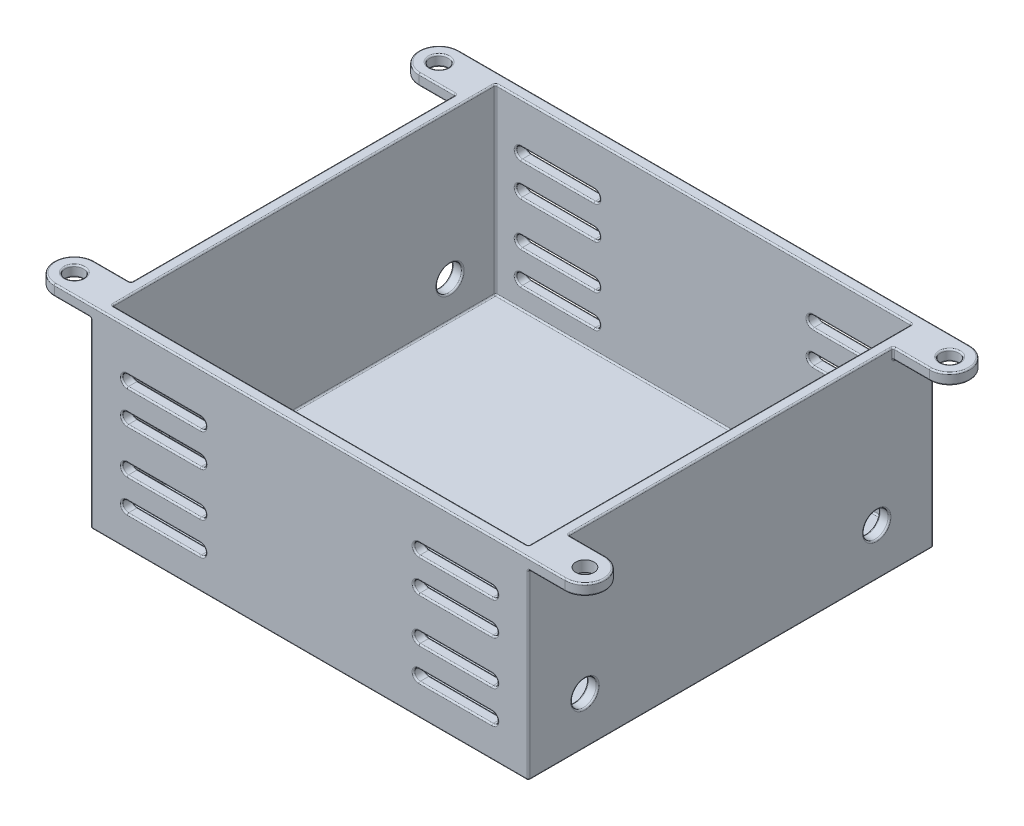
from build123d import *

# Parameters (mm, degrees)
SKETCH1_W                      = 60
SKETCH1_H                      = 55.5
SKETCH1_W_2                    = 57
SKETCH1_H_2                    = 52.5
BOSS_EXTRUDE1_DEPTH            = 25
SKETCH2_W                      = 60
SKETCH2_H                      = 55.5
BOSS_EXTRUDE2_DEPTH            = 1.5
SKETCH4_R                      = 1.25
BOSS_EXTRUDE3_DEPTH            = 1.5
CUT_EXTRUDE1_REACH             = 29.75
CUT_EXTRUDE1_DIRECTION_2_REACH = 29.75
CUT_EXTRUDE2_REACH             = 39.75
SKETCH7_R                      = 1.75
CUT_EXTRUDE2_DIRECTION_2_REACH = 39.75
FILLET1_R                      = 0.2
SKETCH8_R                      = 1.25
CUT_EXTRUDE3_DEPTH             = 10


with BuildPart() as part:
    # Sketch1 → Boss-Extrude1 (new body)
    with BuildSketch(Plane(origin=(0, 0, 0), x_dir=(1, 0, 0), z_dir=(0, 1, 0))):
        Rectangle(SKETCH1_W, SKETCH1_H)
        Rectangle(SKETCH1_W_2, SKETCH1_H_2, mode=Mode.SUBTRACT)
    extrude(amount=-BOSS_EXTRUDE1_DEPTH)

    # Sketch2 → Boss-Extrude2 (add)
    with BuildSketch(Plane.XZ.offset(25)):
        Rectangle(SKETCH2_W, SKETCH2_H)
    extrude(amount=BOSS_EXTRUDE2_DEPTH)

    # Sketch4 → Boss-Extrude3 (add)
    with BuildSketch(Plane(origin=(0, 0, 0), x_dir=(1, 0, 0), z_dir=(0, 1, 0))):
        with BuildLine():
            Line((-30, 22.25), (-30, 27.75))
            Line((-30, 27.75), (-35, 27.75))
            ThreePointArc((-35, 27.75), (-37.75, 25), (-35, 22.25))
            Line((-35, 22.25), (-30, 22.25))
        make_face()
        with Locations((-35, 25)):
            Circle(SKETCH4_R, mode=Mode.SUBTRACT)
        with BuildLine():
            Line((35, 27.75), (30, 27.75))
            Line((30, 27.75), (30, 22.25))
            Line((30, 22.25), (35, 22.25))
            ThreePointArc((35, 22.25), (37.75, 25), (35, 27.75))
        make_face()
        with Locations((35, 25)):
            Circle(SKETCH4_R, mode=Mode.SUBTRACT)
        with BuildLine():
            Line((-30, -27.75), (-30, -22.25))
            Line((-30, -22.25), (-35, -22.25))
            ThreePointArc((-35, -22.25), (-37.75, -25), (-35, -27.75))
            Line((-35, -27.75), (-30, -27.75))
        make_face()
        with Locations((-35, -25)):
            Circle(SKETCH4_R, mode=Mode.SUBTRACT)
        with BuildLine():
            Line((35, -22.25), (30, -22.25))
            Line((30, -22.25), (30, -27.75))
            Line((30, -27.75), (35, -27.75))
            ThreePointArc((35, -27.75), (37.75, -25), (35, -22.25))
        make_face()
    extrude(amount=-BOSS_EXTRUDE3_DEPTH)

    # Cut-Extrude1: up to this face of the body (flat: up to its plane)
    cut_extrude1_end = Plane(part.part.faces().sort_by_distance((0, -13.13317757, -27.75))[0])
    # Sketch5 → Cut-Extrude1 (cut, up to the picked face)
    with BuildSketch(Plane.XY, mode=Mode.PRIVATE) as cut_extrude1_sk1:
        with BuildLine():
            Line((-25, -5.75), (-15, -5.75))
            ThreePointArc((-15, -5.75), (-14.25, -6.5), (-15, -7.25))
            Line((-15, -7.25), (-25, -7.25))
            ThreePointArc((-25, -7.25), (-25.75, -6.5), (-25, -5.75))
        make_face()
    cut_extrude1_tool1 = split(extrude(cut_extrude1_sk1.sketch, amount=-CUT_EXTRUDE1_REACH, mode=Mode.PRIVATE), bisect_by=cut_extrude1_end, keep=Keep.BOTH, mode=Mode.PRIVATE)
    add(cut_extrude1_tool1.solids().sort_by_distance((-20, -6.5, 0))[0], mode=Mode.SUBTRACT)
    # Sketch5 → Cut-Extrude1 (cut, up to the picked face)
    with BuildSketch(Plane.XY, mode=Mode.PRIVATE) as cut_extrude1_sk2:
        with BuildLine():
            Line((-25, -10.25), (-15, -10.25))
            ThreePointArc((-15, -10.25), (-14.25, -11), (-15, -11.75))
            Line((-15, -11.75), (-25, -11.75))
            ThreePointArc((-25, -11.75), (-25.75, -11), (-25, -10.25))
        make_face()
    cut_extrude1_tool2 = split(extrude(cut_extrude1_sk2.sketch, amount=-CUT_EXTRUDE1_REACH, mode=Mode.PRIVATE), bisect_by=cut_extrude1_end, keep=Keep.BOTH, mode=Mode.PRIVATE)
    add(cut_extrude1_tool2.solids().sort_by_distance((-20, -11, 0))[0], mode=Mode.SUBTRACT)
    # Sketch5 → Cut-Extrude1 (cut, up to the picked face)
    with BuildSketch(Plane.XY, mode=Mode.PRIVATE) as cut_extrude1_sk3:
        with BuildLine():
            Line((-25, -22.25), (-15, -22.25))
            ThreePointArc((-15, -22.25), (-14.25, -21.5), (-15, -20.75))
            Line((-15, -20.75), (-25, -20.75))
            ThreePointArc((-25, -20.75), (-25.75, -21.5), (-25, -22.25))
        make_face()
    cut_extrude1_tool3 = split(extrude(cut_extrude1_sk3.sketch, amount=-CUT_EXTRUDE1_REACH, mode=Mode.PRIVATE), bisect_by=cut_extrude1_end, keep=Keep.BOTH, mode=Mode.PRIVATE)
    add(cut_extrude1_tool3.solids().sort_by_distance((-20, -21.5, 0))[0], mode=Mode.SUBTRACT)
    # Sketch5 → Cut-Extrude1 (cut, up to the picked face)
    with BuildSketch(Plane.XY, mode=Mode.PRIVATE) as cut_extrude1_sk4:
        with BuildLine():
            Line((-25, -17.75), (-15, -17.75))
            ThreePointArc((-15, -17.75), (-14.25, -17), (-15, -16.25))
            Line((-15, -16.25), (-25, -16.25))
            ThreePointArc((-25, -16.25), (-25.75, -17), (-25, -17.75))
        make_face()
    cut_extrude1_tool4 = split(extrude(cut_extrude1_sk4.sketch, amount=-CUT_EXTRUDE1_REACH, mode=Mode.PRIVATE), bisect_by=cut_extrude1_end, keep=Keep.BOTH, mode=Mode.PRIVATE)
    add(cut_extrude1_tool4.solids().sort_by_distance((-20, -17, 0))[0], mode=Mode.SUBTRACT)
    # Sketch5 → Cut-Extrude1 (cut, up to the picked face)
    with BuildSketch(Plane.XY, mode=Mode.PRIVATE) as cut_extrude1_sk5:
        with BuildLine():
            Line((25, -5.75), (15, -5.75))
            ThreePointArc((15, -5.75), (14.25, -6.5), (15, -7.25))
            Line((15, -7.25), (25, -7.25))
            ThreePointArc((25, -7.25), (25.75, -6.5), (25, -5.75))
        make_face()
    cut_extrude1_tool5 = split(extrude(cut_extrude1_sk5.sketch, amount=-CUT_EXTRUDE1_REACH, mode=Mode.PRIVATE), bisect_by=cut_extrude1_end, keep=Keep.BOTH, mode=Mode.PRIVATE)
    add(cut_extrude1_tool5.solids().sort_by_distance((20, -6.5, 0))[0], mode=Mode.SUBTRACT)
    # Sketch5 → Cut-Extrude1 (cut, up to the picked face)
    with BuildSketch(Plane.XY, mode=Mode.PRIVATE) as cut_extrude1_sk6:
        with BuildLine():
            Line((25, -10.25), (15, -10.25))
            ThreePointArc((15, -10.25), (14.25, -11), (15, -11.75))
            Line((15, -11.75), (25, -11.75))
            ThreePointArc((25, -11.75), (25.75, -11), (25, -10.25))
        make_face()
    cut_extrude1_tool6 = split(extrude(cut_extrude1_sk6.sketch, amount=-CUT_EXTRUDE1_REACH, mode=Mode.PRIVATE), bisect_by=cut_extrude1_end, keep=Keep.BOTH, mode=Mode.PRIVATE)
    add(cut_extrude1_tool6.solids().sort_by_distance((20, -11, 0))[0], mode=Mode.SUBTRACT)
    # Sketch5 → Cut-Extrude1 (cut, up to the picked face)
    with BuildSketch(Plane.XY, mode=Mode.PRIVATE) as cut_extrude1_sk7:
        with BuildLine():
            Line((25, -22.25), (15, -22.25))
            ThreePointArc((15, -22.25), (14.25, -21.5), (15, -20.75))
            Line((15, -20.75), (25, -20.75))
            ThreePointArc((25, -20.75), (25.75, -21.5), (25, -22.25))
        make_face()
    cut_extrude1_tool7 = split(extrude(cut_extrude1_sk7.sketch, amount=-CUT_EXTRUDE1_REACH, mode=Mode.PRIVATE), bisect_by=cut_extrude1_end, keep=Keep.BOTH, mode=Mode.PRIVATE)
    add(cut_extrude1_tool7.solids().sort_by_distance((20, -21.5, 0))[0], mode=Mode.SUBTRACT)
    # Sketch5 → Cut-Extrude1 (cut, up to the picked face)
    with BuildSketch(Plane.XY, mode=Mode.PRIVATE) as cut_extrude1_sk8:
        with BuildLine():
            Line((25, -17.75), (15, -17.75))
            ThreePointArc((15, -17.75), (14.25, -17), (15, -16.25))
            Line((15, -16.25), (25, -16.25))
            ThreePointArc((25, -16.25), (25.75, -17), (25, -17.75))
        make_face()
    cut_extrude1_tool8 = split(extrude(cut_extrude1_sk8.sketch, amount=-CUT_EXTRUDE1_REACH, mode=Mode.PRIVATE), bisect_by=cut_extrude1_end, keep=Keep.BOTH, mode=Mode.PRIVATE)
    add(cut_extrude1_tool8.solids().sort_by_distance((20, -17, 0))[0], mode=Mode.SUBTRACT)

    # Cut-Extrude1 direction 2: up to this face of the body (flat: up to its plane)
    cut_extrude1_direction_2_end = Plane(part.part.faces().sort_by_distance((0, -13.13317757, 27.75))[0])
    # Sketch5 → Cut-Extrude1 direction 2 (cut, up to the picked face)
    with BuildSketch(Plane.XY, mode=Mode.PRIVATE) as cut_extrude1_direction_2_sk1:
        with BuildLine():
            Line((-25, -5.75), (-15, -5.75))
            ThreePointArc((-15, -5.75), (-14.25, -6.5), (-15, -7.25))
            Line((-15, -7.25), (-25, -7.25))
            ThreePointArc((-25, -7.25), (-25.75, -6.5), (-25, -5.75))
        make_face()
    cut_extrude1_direction_2_tool1 = split(extrude(cut_extrude1_direction_2_sk1.sketch, amount=CUT_EXTRUDE1_DIRECTION_2_REACH, mode=Mode.PRIVATE), bisect_by=cut_extrude1_direction_2_end, keep=Keep.BOTH, mode=Mode.PRIVATE)
    add(cut_extrude1_direction_2_tool1.solids().sort_by_distance((-20, -6.5, 0))[0], mode=Mode.SUBTRACT)
    # Sketch5 → Cut-Extrude1 direction 2 (cut, up to the picked face)
    with BuildSketch(Plane.XY, mode=Mode.PRIVATE) as cut_extrude1_direction_2_sk2:
        with BuildLine():
            Line((-25, -10.25), (-15, -10.25))
            ThreePointArc((-15, -10.25), (-14.25, -11), (-15, -11.75))
            Line((-15, -11.75), (-25, -11.75))
            ThreePointArc((-25, -11.75), (-25.75, -11), (-25, -10.25))
        make_face()
    cut_extrude1_direction_2_tool2 = split(extrude(cut_extrude1_direction_2_sk2.sketch, amount=CUT_EXTRUDE1_DIRECTION_2_REACH, mode=Mode.PRIVATE), bisect_by=cut_extrude1_direction_2_end, keep=Keep.BOTH, mode=Mode.PRIVATE)
    add(cut_extrude1_direction_2_tool2.solids().sort_by_distance((-20, -11, 0))[0], mode=Mode.SUBTRACT)
    # Sketch5 → Cut-Extrude1 direction 2 (cut, up to the picked face)
    with BuildSketch(Plane.XY, mode=Mode.PRIVATE) as cut_extrude1_direction_2_sk3:
        with BuildLine():
            Line((-25, -22.25), (-15, -22.25))
            ThreePointArc((-15, -22.25), (-14.25, -21.5), (-15, -20.75))
            Line((-15, -20.75), (-25, -20.75))
            ThreePointArc((-25, -20.75), (-25.75, -21.5), (-25, -22.25))
        make_face()
    cut_extrude1_direction_2_tool3 = split(extrude(cut_extrude1_direction_2_sk3.sketch, amount=CUT_EXTRUDE1_DIRECTION_2_REACH, mode=Mode.PRIVATE), bisect_by=cut_extrude1_direction_2_end, keep=Keep.BOTH, mode=Mode.PRIVATE)
    add(cut_extrude1_direction_2_tool3.solids().sort_by_distance((-20, -21.5, 0))[0], mode=Mode.SUBTRACT)
    # Sketch5 → Cut-Extrude1 direction 2 (cut, up to the picked face)
    with BuildSketch(Plane.XY, mode=Mode.PRIVATE) as cut_extrude1_direction_2_sk4:
        with BuildLine():
            Line((-25, -17.75), (-15, -17.75))
            ThreePointArc((-15, -17.75), (-14.25, -17), (-15, -16.25))
            Line((-15, -16.25), (-25, -16.25))
            ThreePointArc((-25, -16.25), (-25.75, -17), (-25, -17.75))
        make_face()
    cut_extrude1_direction_2_tool4 = split(extrude(cut_extrude1_direction_2_sk4.sketch, amount=CUT_EXTRUDE1_DIRECTION_2_REACH, mode=Mode.PRIVATE), bisect_by=cut_extrude1_direction_2_end, keep=Keep.BOTH, mode=Mode.PRIVATE)
    add(cut_extrude1_direction_2_tool4.solids().sort_by_distance((-20, -17, 0))[0], mode=Mode.SUBTRACT)
    # Sketch5 → Cut-Extrude1 direction 2 (cut, up to the picked face)
    with BuildSketch(Plane.XY, mode=Mode.PRIVATE) as cut_extrude1_direction_2_sk5:
        with BuildLine():
            Line((25, -5.75), (15, -5.75))
            ThreePointArc((15, -5.75), (14.25, -6.5), (15, -7.25))
            Line((15, -7.25), (25, -7.25))
            ThreePointArc((25, -7.25), (25.75, -6.5), (25, -5.75))
        make_face()
    cut_extrude1_direction_2_tool5 = split(extrude(cut_extrude1_direction_2_sk5.sketch, amount=CUT_EXTRUDE1_DIRECTION_2_REACH, mode=Mode.PRIVATE), bisect_by=cut_extrude1_direction_2_end, keep=Keep.BOTH, mode=Mode.PRIVATE)
    add(cut_extrude1_direction_2_tool5.solids().sort_by_distance((20, -6.5, 0))[0], mode=Mode.SUBTRACT)
    # Sketch5 → Cut-Extrude1 direction 2 (cut, up to the picked face)
    with BuildSketch(Plane.XY, mode=Mode.PRIVATE) as cut_extrude1_direction_2_sk6:
        with BuildLine():
            Line((25, -10.25), (15, -10.25))
            ThreePointArc((15, -10.25), (14.25, -11), (15, -11.75))
            Line((15, -11.75), (25, -11.75))
            ThreePointArc((25, -11.75), (25.75, -11), (25, -10.25))
        make_face()
    cut_extrude1_direction_2_tool6 = split(extrude(cut_extrude1_direction_2_sk6.sketch, amount=CUT_EXTRUDE1_DIRECTION_2_REACH, mode=Mode.PRIVATE), bisect_by=cut_extrude1_direction_2_end, keep=Keep.BOTH, mode=Mode.PRIVATE)
    add(cut_extrude1_direction_2_tool6.solids().sort_by_distance((20, -11, 0))[0], mode=Mode.SUBTRACT)
    # Sketch5 → Cut-Extrude1 direction 2 (cut, up to the picked face)
    with BuildSketch(Plane.XY, mode=Mode.PRIVATE) as cut_extrude1_direction_2_sk7:
        with BuildLine():
            Line((25, -22.25), (15, -22.25))
            ThreePointArc((15, -22.25), (14.25, -21.5), (15, -20.75))
            Line((15, -20.75), (25, -20.75))
            ThreePointArc((25, -20.75), (25.75, -21.5), (25, -22.25))
        make_face()
    cut_extrude1_direction_2_tool7 = split(extrude(cut_extrude1_direction_2_sk7.sketch, amount=CUT_EXTRUDE1_DIRECTION_2_REACH, mode=Mode.PRIVATE), bisect_by=cut_extrude1_direction_2_end, keep=Keep.BOTH, mode=Mode.PRIVATE)
    add(cut_extrude1_direction_2_tool7.solids().sort_by_distance((20, -21.5, 0))[0], mode=Mode.SUBTRACT)
    # Sketch5 → Cut-Extrude1 direction 2 (cut, up to the picked face)
    with BuildSketch(Plane.XY, mode=Mode.PRIVATE) as cut_extrude1_direction_2_sk8:
        with BuildLine():
            Line((25, -17.75), (15, -17.75))
            ThreePointArc((15, -17.75), (14.25, -17), (15, -16.25))
            Line((15, -16.25), (25, -16.25))
            ThreePointArc((25, -16.25), (25.75, -17), (25, -17.75))
        make_face()
    cut_extrude1_direction_2_tool8 = split(extrude(cut_extrude1_direction_2_sk8.sketch, amount=CUT_EXTRUDE1_DIRECTION_2_REACH, mode=Mode.PRIVATE), bisect_by=cut_extrude1_direction_2_end, keep=Keep.BOTH, mode=Mode.PRIVATE)
    add(cut_extrude1_direction_2_tool8.solids().sort_by_distance((20, -17, 0))[0], mode=Mode.SUBTRACT)

    # Cut-Extrude2: up to this face of the body (flat: up to its plane)
    cut_extrude2_end = Plane(part.part.faces().sort_by_distance((30, -13.391825683, 0))[0])
    # Sketch7 → Cut-Extrude2 (cut, up to the picked face)
    with BuildSketch(Plane(origin=(0, 0, 0), x_dir=(0, 0, -1), z_dir=(1, 0, 0)), mode=Mode.PRIVATE) as cut_extrude2_sk1:
        with Locations((-20, -20)):
            Circle(SKETCH7_R)
    cut_extrude2_tool1 = split(extrude(cut_extrude2_sk1.sketch, amount=CUT_EXTRUDE2_REACH, mode=Mode.PRIVATE), bisect_by=cut_extrude2_end, keep=Keep.BOTH, mode=Mode.PRIVATE)
    add(cut_extrude2_tool1.solids().sort_by_distance((0, -20, 20))[0], mode=Mode.SUBTRACT)
    # Sketch7 → Cut-Extrude2 (cut, up to the picked face)
    with BuildSketch(Plane(origin=(0, 0, 0), x_dir=(0, 0, -1), z_dir=(1, 0, 0)), mode=Mode.PRIVATE) as cut_extrude2_sk2:
        with Locations((20, -20)):
            Circle(SKETCH7_R)
    cut_extrude2_tool2 = split(extrude(cut_extrude2_sk2.sketch, amount=CUT_EXTRUDE2_REACH, mode=Mode.PRIVATE), bisect_by=cut_extrude2_end, keep=Keep.BOTH, mode=Mode.PRIVATE)
    add(cut_extrude2_tool2.solids().sort_by_distance((0, -20, -20))[0], mode=Mode.SUBTRACT)

    # Cut-Extrude2 direction 2: up to this face of the body (flat: up to its plane)
    cut_extrude2_direction_2_end = Plane(part.part.faces().sort_by_distance((-30, -13.391825683, 0))[0])
    # Sketch7 → Cut-Extrude2 direction 2 (cut, up to the picked face)
    with BuildSketch(Plane(origin=(0, 0, 0), x_dir=(0, 0, -1), z_dir=(1, 0, 0)), mode=Mode.PRIVATE) as cut_extrude2_direction_2_sk1:
        with Locations((-20, -20)):
            Circle(SKETCH7_R)
    cut_extrude2_direction_2_tool1 = split(extrude(cut_extrude2_direction_2_sk1.sketch, amount=-CUT_EXTRUDE2_DIRECTION_2_REACH, mode=Mode.PRIVATE), bisect_by=cut_extrude2_direction_2_end, keep=Keep.BOTH, mode=Mode.PRIVATE)
    add(cut_extrude2_direction_2_tool1.solids().sort_by_distance((0, -20, 20))[0], mode=Mode.SUBTRACT)
    # Sketch7 → Cut-Extrude2 direction 2 (cut, up to the picked face)
    with BuildSketch(Plane(origin=(0, 0, 0), x_dir=(0, 0, -1), z_dir=(1, 0, 0)), mode=Mode.PRIVATE) as cut_extrude2_direction_2_sk2:
        with Locations((20, -20)):
            Circle(SKETCH7_R)
    cut_extrude2_direction_2_tool2 = split(extrude(cut_extrude2_direction_2_sk2.sketch, amount=-CUT_EXTRUDE2_DIRECTION_2_REACH, mode=Mode.PRIVATE), bisect_by=cut_extrude2_direction_2_end, keep=Keep.BOTH, mode=Mode.PRIVATE)
    add(cut_extrude2_direction_2_tool2.solids().sort_by_distance((0, -20, -20))[0], mode=Mode.SUBTRACT)

    # Fillet1
    fillet1_edges = [part.edges().sort_by_distance(p)[0] for p in [
        (0, 0, 27.75),
        (0, 0, -27.75),
        (0, -25, 26.25),
        (0, 0, -26.25),
        (-28.5, 0, 0),
        (0, 0, 26.25),
        (28.5, 0, 0),
        (20, -5.75, -26.25),
        (20, -5.75, -27.75),
        (20, -5.75, 26.25),
        (14.25, -6.5, -26.25),
        (14.25, -6.5, -27.75),
        (14.25, -6.5, 26.25),
        (30, -14, 27.75),
        (20, -7.25, -26.25),
        (20, -7.25, -27.75),
        (20, -7.25, 26.25),
        (25.75, -6.5, -26.25),
        (25.75, -6.5, -27.75),
        (25.75, -6.5, 26.25),
        (-30, -14, 27.75),
        (20, -7.25, 27.75),
        (25.75, -6.5, 27.75),
        (20, -5.75, 27.75),
        (14.25, -6.5, 27.75),
        (-28.5, -25, 0),
        (-30, -14, -27.75),
        (30, -14, -27.75),
        (28.5, -12.5, -26.25),
        (-28.5, -12.5, -26.25),
        (-28.5, -12.5, 26.25),
        (28.5, -12.5, 26.25),
        (-20, -17.75, -26.25),
        (-20, -17.75, -27.75),
        (-20, -17.75, 26.25),
        (-14.25, -17, -26.25),
        (-14.25, -17, -27.75),
        (-14.25, -17, 26.25),
        (-20, -16.25, -26.25),
        (-20, -16.25, -27.75),
        (-20, -16.25, 26.25),
        (-25.75, -17, -26.25),
        (-25.75, -17, -27.75),
        (-25.75, -17, 26.25),
        (-20, -16.25, 27.75),
        (-25.75, -17, 27.75),
        (-20, -17.75, 27.75),
        (-14.25, -17, 27.75),
        (-20, -22.25, -26.25),
        (-20, -22.25, -27.75),
        (-20, -22.25, 26.25),
        (-14.25, -21.5, -26.25),
        (-14.25, -21.5, -27.75),
        (-14.25, -21.5, 26.25),
        (-20, -20.75, -26.25),
        (-20, -20.75, -27.75),
        (-20, -20.75, 26.25),
        (-25.75, -21.5, -26.25),
        (-25.75, -21.5, -27.75),
        (-25.75, -21.5, 26.25),
        (-20, -20.75, 27.75),
        (-25.75, -21.5, 27.75),
        (-20, -22.25, 27.75),
        (-14.25, -21.5, 27.75),
        (-20, -11.75, -26.25),
        (-20, -11.75, -27.75),
        (-20, -11.75, 26.25),
        (-14.25, -11, -26.25),
        (-14.25, -11, -27.75),
        (-14.25, -11, 26.25),
        (-20, -10.25, -26.25),
        (-20, -10.25, -27.75),
        (-20, -10.25, 26.25),
        (-25.75, -11, -26.25),
        (-25.75, -11, -27.75),
        (-25.75, -11, 26.25),
        (-20, -10.25, 27.75),
        (-25.75, -11, 27.75),
        (-20, -11.75, 27.75),
        (-14.25, -11, 27.75),
        (20, -16.25, -26.25),
        (20, -16.25, -27.75),
        (20, -16.25, 26.25),
        (14.25, -17, -26.25),
        (14.25, -17, -27.75),
        (14.25, -17, 26.25),
        (20, -17.75, -26.25),
        (20, -17.75, -27.75),
        (20, -17.75, 26.25),
        (25.75, -17, -26.25),
        (25.75, -17, -27.75),
        (25.75, -17, 26.25),
        (20, -17.75, 27.75),
        (25.75, -17, 27.75),
        (20, -16.25, 27.75),
        (14.25, -17, 27.75),
        (20, -20.75, -26.25),
        (20, -20.75, -27.75),
        (20, -20.75, 26.25),
        (14.25, -21.5, -26.25),
        (14.25, -21.5, -27.75),
        (14.25, -21.5, 26.25),
        (20, -22.25, -26.25),
        (20, -22.25, -27.75),
        (20, -22.25, 26.25),
        (0, -25, -26.25),
        (25.75, -21.5, -26.25),
        (25.75, -21.5, -27.75),
        (25.75, -21.5, 26.25),
        (20, -22.25, 27.75),
        (25.75, -21.5, 27.75),
        (20, -20.75, 27.75),
        (14.25, -21.5, 27.75),
        (20, -10.25, -26.25),
        (20, -10.25, -27.75),
        (20, -10.25, 26.25),
        (14.25, -11, -26.25),
        (14.25, -11, -27.75),
        (14.25, -11, 26.25),
        (20, -11.75, -26.25),
        (20, -11.75, -27.75),
        (20, -11.75, 26.25),
        (25.75, -11, -26.25),
        (25.75, -11, -27.75),
        (25.75, -11, 26.25),
        (20, -11.75, 27.75),
        (25.75, -11, 27.75),
        (20, -10.25, 27.75),
        (14.25, -11, 27.75),
        (-20, -7.25, -26.25),
        (-20, -7.25, -27.75),
        (-20, -7.25, 26.25),
        (-14.25, -6.5, -26.25),
        (-14.25, -6.5, -27.75),
        (-14.25, -6.5, 26.25),
        (-20, -5.75, -26.25),
        (-20, -5.75, -27.75),
        (-20, -5.75, 26.25),
        (-25.75, -6.5, -26.25),
        (-25.75, -6.5, -27.75),
        (-25.75, -6.5, 26.25),
        (-20, -5.75, 27.75),
        (-25.75, -6.5, 27.75),
        (-20, -7.25, 27.75),
        (-14.25, -6.5, 27.75),
        (0, -26.5, -27.75),
        (30, -26.5, 0),
        (0, -26.5, 27.75),
        (-30, -26.5, 0),
        (-30, -20, 21.75),
        (28.5, -20, 21.75),
        (-28.5, -20, 21.75),
        (30, -20, 21.75),
        (-30, -20, -18.25),
        (28.5, -20, -18.25),
        (-28.5, -20, -18.25),
        (30, -20, -18.25),
        (-30, 0, 0),
        (-32.5, -1.5, -27.75),
        (-32.5, -1.5, -22.25),
        (-30, -0.75, -22.25),
        (-37.75, -1.5, -25),
        (-36.25, 0, -25),
        (-30, -1.5, -25),
        (-36.25, -1.5, -25),
        (-37.75, 0, -25),
        (-32.5, 0, -22.25),
        (-32.5, 0, 22.25),
        (-30, -0.75, 22.25),
        (-32.5, -1.5, 27.75),
        (-37.75, -1.5, 25),
        (-36.25, 0, 25),
        (-32.5, -1.5, 22.25),
        (-30, -1.5, 25),
        (-36.25, -1.5, 25),
        (-37.75, 0, 25),
        (28.5, -25, 0),
        (37.75, -1.5, -25),
        (32.5, 0, -22.25),
        (30, -0.75, -22.25),
        (33.75, 0, -25),
        (32.5, -1.5, -27.75),
        (33.75, -1.5, -25),
        (32.5, -1.5, -22.25),
        (30, -1.5, -25),
        (37.75, 0, -25),
        (30, 0, 0),
        (32.5, -1.5, 22.25),
        (30, -0.75, 22.25),
        (32.5, -1.5, 27.75),
        (30, -1.5, 25),
        (37.75, 0, 25),
        (32.5, 0, 22.25),
        (37.75, -1.5, 25),
    ]]
    fillet(fillet1_edges, radius=FILLET1_R)

    # Sketch8 → Cut-Extrude3 (cut)
    with BuildSketch(Plane(origin=(0, 0, 0), x_dir=(1, 0, 0), z_dir=(0, 1, 0))):
        with Locations((35, -25)):
            Circle(SKETCH8_R)
    extrude(amount=-CUT_EXTRUDE3_DEPTH, mode=Mode.SUBTRACT)


solid = part.part
